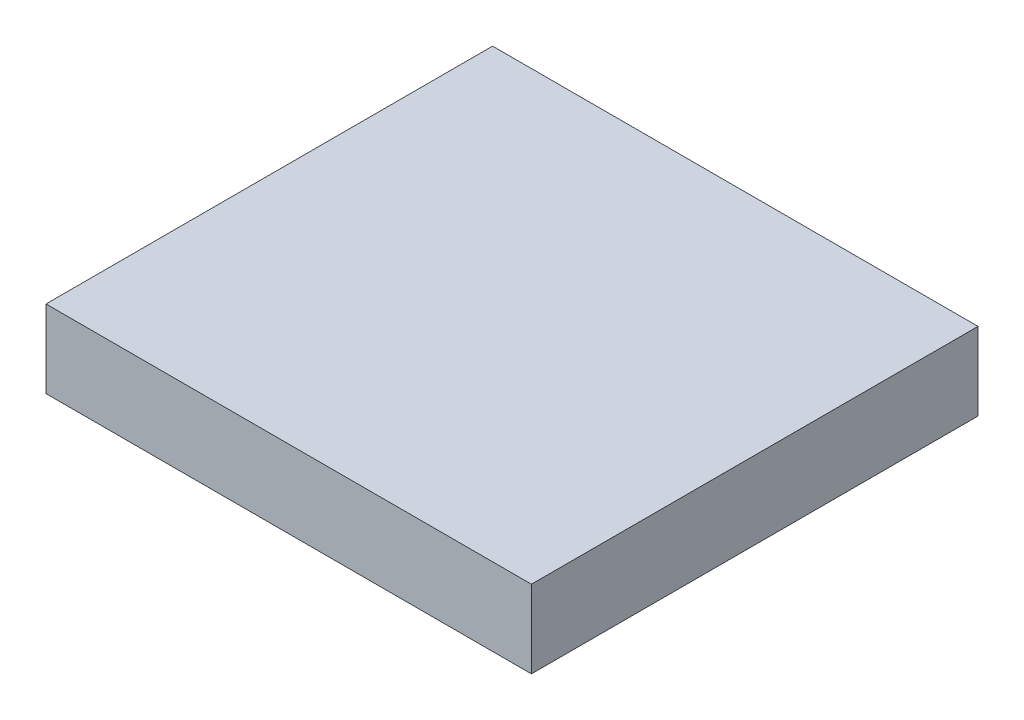
from build123d import *

# Parameters (mm, degrees)
SKETCH1_W           = 500
SKETCH1_H           = 460
BOSS_EXTRUDE1_DEPTH = 80


with BuildPart() as part:
    # Sketch1 → Boss-Extrude1 (new body)
    with BuildSketch(Plane(origin=(0, 0, 0), x_dir=(1, 0, 0), z_dir=(0, 1, 0))):
        Rectangle(SKETCH1_W, SKETCH1_H)
    extrude(amount=BOSS_EXTRUDE1_DEPTH)


solid = part.part
